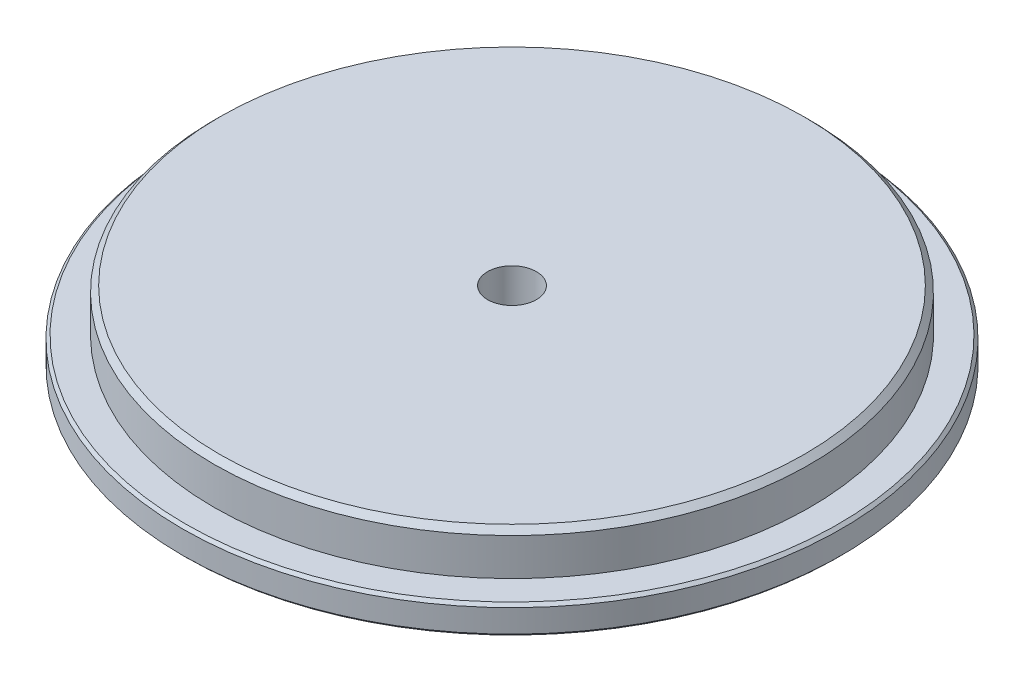
from build123d import *

# Parameters (mm, degrees)
SKETCH_1_R          = 115
EXTRUDE_1_DEPTH     = 10
SKETCH_2_R          = 104
EXTRUDE_2_DEPTH     = 15
CHAMFER_1_SIZE      = 1
CHAMFER_2_SIZE      = 2
SKETCH_3_R          = 8.5
CUT_EXTRUDE_1_DEPTH = 25


with BuildPart() as part:
    # Эскиз1 → Бобышка-Вытянуть1 (new body)
    with BuildSketch(Plane(origin=(0, 0, 0), x_dir=(1, 0, 0), z_dir=(0, 1, 0))):
        Circle(SKETCH_1_R)
    extrude(amount=EXTRUDE_1_DEPTH)

    # Эскиз2 → Бобышка-Вытянуть2 (add)
    with BuildSketch(Plane(origin=(0, 10, 0), x_dir=(1, 0, 0), z_dir=(0, 1, 0))):
        Circle(SKETCH_2_R)
    extrude(amount=EXTRUDE_2_DEPTH)

    # Фаска1
    chamfer_1_edges = [part.edges().sort_by_distance(p)[0] for p in [
        (-115, 0, 0),
        (-115, 10, 0),
    ]]
    chamfer(chamfer_1_edges, length=CHAMFER_1_SIZE)

    # Фаска2
    chamfer_2_edges = [part.edges().sort_by_distance(p)[0] for p in [
        (-104, 25, 0),
    ]]
    chamfer(chamfer_2_edges, length=CHAMFER_2_SIZE)

    # Эскиз3 → Вырез-Вытянуть1 (cut)
    with BuildSketch(Plane(origin=(0, 25, 0), x_dir=(1, 0, 0), z_dir=(0, 1, 0))):
        Circle(SKETCH_3_R)
    extrude(amount=-CUT_EXTRUDE_1_DEPTH, mode=Mode.SUBTRACT)


solid = part.part
